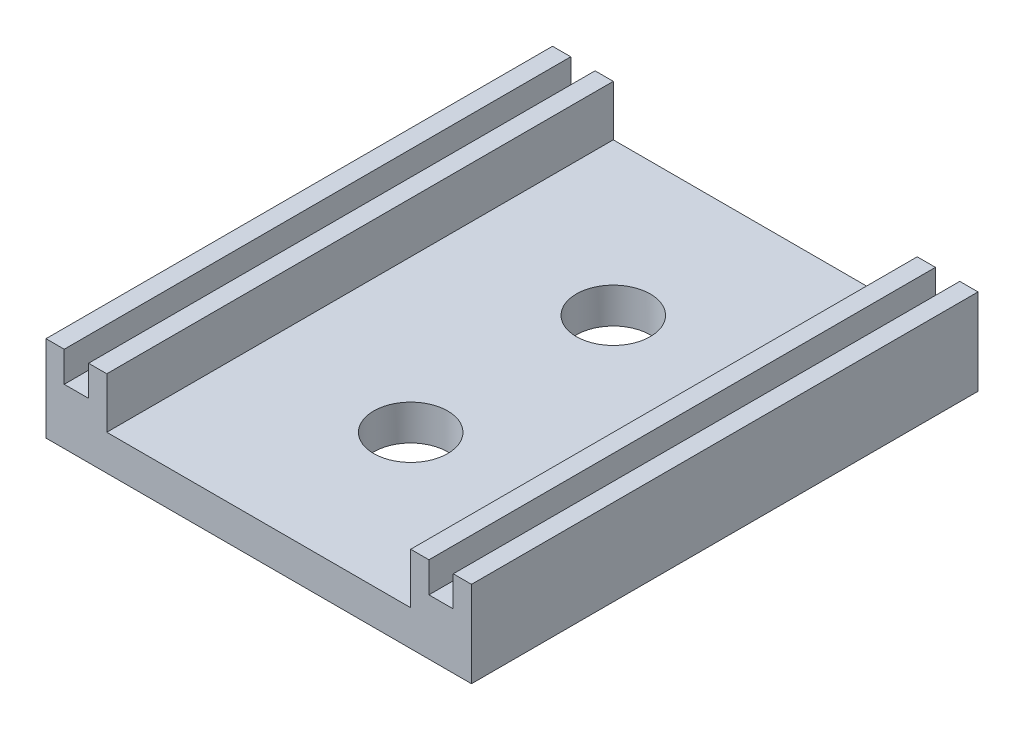
from build123d import *

# Parameters (mm, degrees)
SKETCH1_W               = 40
SKETCH1_H               = 50
BOSS_EXTRUDE1_DEPTH     = 3.5
SKETCH2_W               = 40
SKETCH2_H               = 4
BOSS_EXTRUDE2_DEPTH     = 5
SKETCH3_W               = 4
SKETCH3_H               = 46
BOSS_EXTRUDE3_DEPTH     = 5
SKETCH4_W               = 2.4
SKETCH4_H               = 50
CUT_EXTRUDE1_DEPTH      = 3
SKETCH18_W              = 50
SKETCH18_H              = 8.5
BOSS_EXTRUDE8_DEPTH     = 1
SKETCH19_R              = 3.65
CUT_EXTRUDE2_DEPTH      = 6
CUT_EXTRUDE2_DEPTH_BACK = 4.5
SKETCH20_W              = 32
SKETCH20_H              = 4
CUT_EXTRUDE3_DEPTH      = 5
SKETCH21_W              = 50
SKETCH21_H              = 5
BOSS_EXTRUDE9_DEPTH     = 1


with BuildPart() as part:
    # Sketch1 → Boss-Extrude1 (new body)
    with BuildSketch(Plane(origin=(0, 0, 0), x_dir=(1, 0, 0), z_dir=(0, 1, 0))):
        Rectangle(SKETCH1_W, SKETCH1_H)
    extrude(amount=BOSS_EXTRUDE1_DEPTH)

    # Sketch2 → Boss-Extrude2 (add)
    with BuildSketch(Plane(origin=(0, 3.5, 0), x_dir=(1, 0, 0), z_dir=(0, 1, 0))):
        with Locations((0, 23)):
            Rectangle(SKETCH2_W, SKETCH2_H)
    extrude(amount=BOSS_EXTRUDE2_DEPTH)

    # Sketch3 → Boss-Extrude3 (add)
    with BuildSketch(Plane(origin=(0, 3.5, 0), x_dir=(1, 0, 0), z_dir=(0, 1, 0))):
        with Locations((-18, -2)):
            Rectangle(SKETCH3_W, SKETCH3_H)
    boss_extrude3 = extrude(amount=BOSS_EXTRUDE3_DEPTH)

    # Sketch4 → Cut-Extrude1 (cut)
    with BuildSketch(Plane(origin=(0, 8.5, 0), x_dir=(1, 0, 0), z_dir=(0, 1, 0))):
        with Locations((-18, 0)):
            Rectangle(SKETCH4_W, SKETCH4_H)
    cut_extrude1 = extrude(amount=-CUT_EXTRUDE1_DEPTH, mode=Mode.SUBTRACT)

    # Mirror1: Boss-Extrude3, Cut-Extrude1 across plane
    add(boss_extrude3.mirror(Plane(origin=(0, 0, 0), x_dir=(0, 0, 1), z_dir=(1, 0, 0))))
    add(cut_extrude1.mirror(Plane(origin=(0, 0, 0), x_dir=(0, 0, 1), z_dir=(1, 0, 0))), mode=Mode.SUBTRACT)

    # Sketch18 → Boss-Extrude8 (add)
    with BuildSketch(Plane.ZY.offset(20)):
        with Locations((0, 4.25)):
            Rectangle(SKETCH18_W, SKETCH18_H)
    boss_extrude8 = extrude(amount=BOSS_EXTRUDE8_DEPTH)

    # Mirror5: Boss-Extrude8 across plane
    add(boss_extrude8.mirror(Plane(origin=(0, 0, 0), x_dir=(0, 0, 1), z_dir=(1, 0, 0))))

    # Sketch19 → Cut-Extrude2 (cut, two sides)
    with BuildSketch(Plane(origin=(0, 3.5, 0), x_dir=(1, 0, 0), z_dir=(0, 1, 0))) as cut_extrude2_sk:
        with Locations((0, -10)):
            Circle(SKETCH19_R)
        with Locations((0, 10)):
            Circle(SKETCH19_R)
    extrude(amount=CUT_EXTRUDE2_DEPTH, mode=Mode.SUBTRACT)
    extrude(cut_extrude2_sk.sketch, amount=-CUT_EXTRUDE2_DEPTH_BACK, mode=Mode.SUBTRACT)

    # Sketch20 → Cut-Extrude3 (cut)
    with BuildSketch(Plane(origin=(0, 8.5, 0), x_dir=(1, 0, 0), z_dir=(0, 1, 0))):
        with Locations((0, 23)):
            Rectangle(SKETCH20_W, SKETCH20_H)
    extrude(amount=-CUT_EXTRUDE3_DEPTH, mode=Mode.SUBTRACT)

    # Sketch21 → Boss-Extrude9 (add)
    with BuildSketch(Plane(origin=(-16, 0, 0), x_dir=(0, 0, -1), z_dir=(1, 0, 0))):
        with Locations((0, 6)):
            Rectangle(SKETCH21_W, SKETCH21_H)
    boss_extrude9 = extrude(amount=BOSS_EXTRUDE9_DEPTH)

    # Mirror6: Boss-Extrude9 across plane
    add(boss_extrude9.mirror(Plane(origin=(0, 0, 0), x_dir=(0, 0, 1), z_dir=(1, 0, 0))))


solid = part.part
